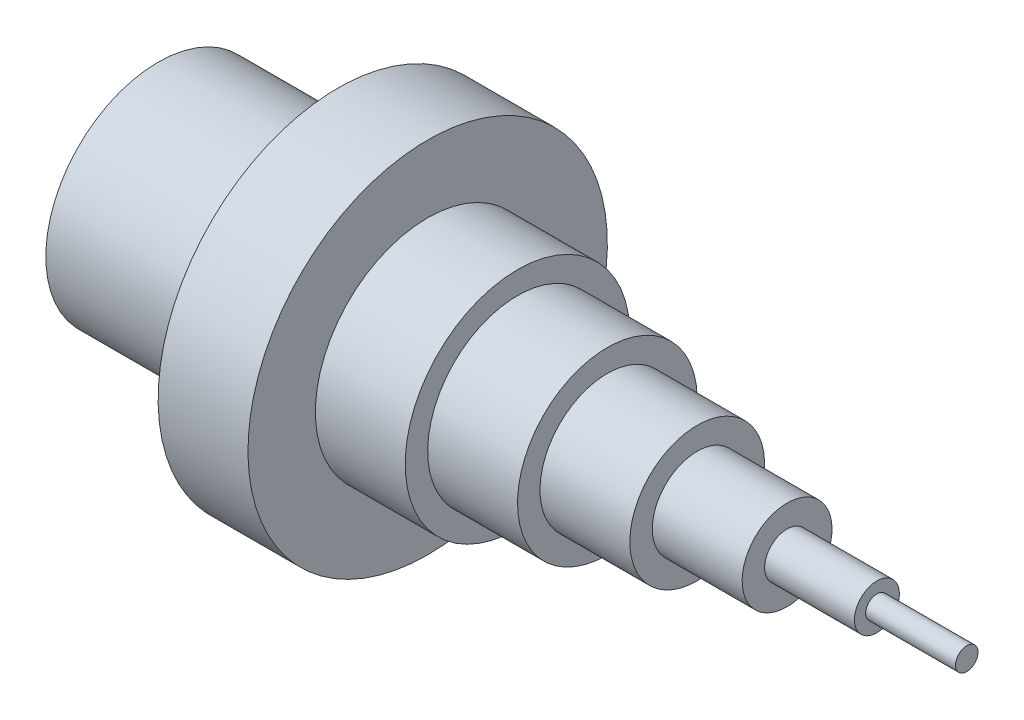
from build123d import *


with BuildPart() as part:
    # Sketch1 → Revolve2 (revolve)
    with BuildSketch(Plane.XY, mode=Mode.PRIVATE) as revolve2_sk:
        Polygon((-40.225741407, 20), (-40.225741407, 25), (-0.225741407, 25), (-0.225741407, 40), (19.774258593, 40), (19.774258593, 25), (39.774258593, 25), (39.774258593, 20), (59.774258593, 20), (59.774258593, 15), (79.774258593, 15), (79.774258593, 10), (99.774258593, 10), (99.774258593, 5), (119.774258593, 5), (119.774258593, 2.5), (139.774258593, 2.5), (139.774258593, 0), (-0.122966015, 0), (-0.122966015, 20), align=None)
    revolve(revolve2_sk.sketch.rotate(Axis((-74.790093539, 0, 0), (1, 0, 0)), 180), axis=Axis((-74.790093539, 0, 0), (1, 0, 0)))  # turned: the seam where the file's is


solid = part.part
